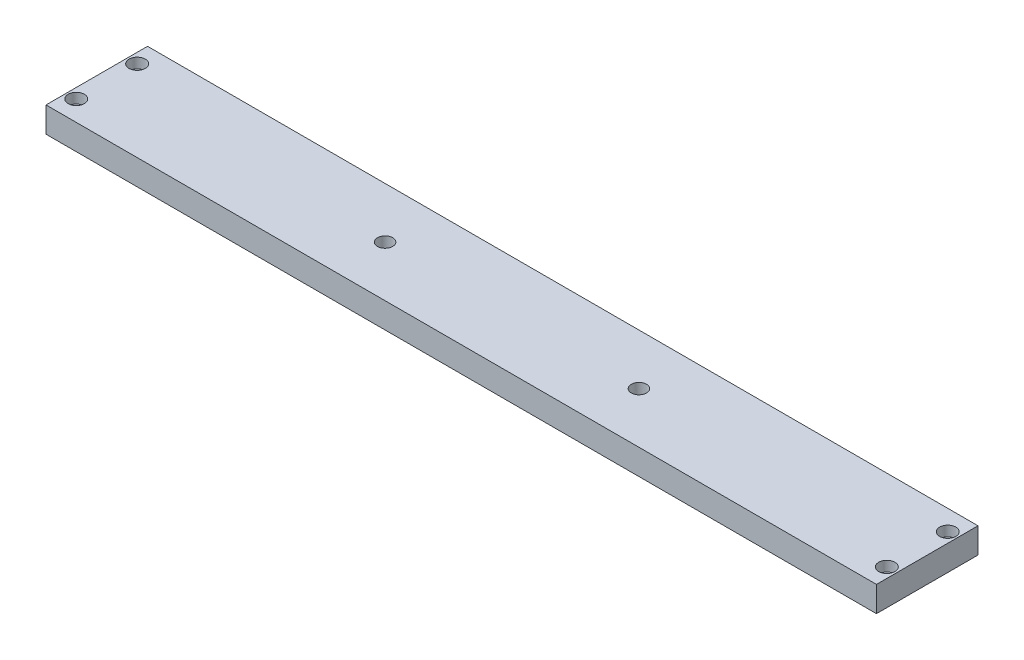
from build123d import *

# Parameters (mm, degrees)
SKETCH1_W           = 163.57
SKETCH1_H           = 20
SKETCH1_R           = 1
BOSS_EXTRUDE1_DEPTH = 5
SKETCH2_R           = 1.6
CUT_EXTRUDE1_DEPTH  = 2
SKETCH3_R           = 1.5
CUT_EXTRUDE2_DEPTH  = 10


with BuildPart() as part:
    # Sketch1 → Boss-Extrude1 (new body)
    with BuildSketch(Plane(origin=(0, 0, 0), x_dir=(1, 0, 0), z_dir=(0, 1, 0))):
        Rectangle(SKETCH1_W, SKETCH1_H)
        with Locations((-79.825, 6)):
            Circle(SKETCH1_R, mode=Mode.SUBTRACT)
        with Locations((-79.825, -6)):
            Circle(SKETCH1_R, mode=Mode.SUBTRACT)
        with Locations((79.825, 6)):
            Circle(SKETCH1_R, mode=Mode.SUBTRACT)
        with Locations((79.825, -6)):
            Circle(SKETCH1_R, mode=Mode.SUBTRACT)
    extrude(amount=BOSS_EXTRUDE1_DEPTH)

    # Sketch2 → Cut-Extrude1 (cut)
    with BuildSketch(Plane(origin=(0, 5, 0), x_dir=(1, 0, 0), z_dir=(0, 1, 0))):
        with Locations((-79.825, 6)):
            Circle(SKETCH2_R)
        with Locations((-79.825, -6)):
            Circle(SKETCH2_R)
        with Locations((79.825, 6)):
            Circle(SKETCH2_R)
        with Locations((79.825, -6)):
            Circle(SKETCH2_R)
    extrude(amount=-CUT_EXTRUDE1_DEPTH, mode=Mode.SUBTRACT)

    # Sketch3 → Cut-Extrude2 (cut)
    with BuildSketch(Plane(origin=(0, 5, 0), x_dir=(1, 0, 0), z_dir=(0, 1, 0))):
        with Locations((-25, 0)):
            Circle(SKETCH3_R)
        with Locations((25, 0)):
            Circle(SKETCH3_R)
    extrude(amount=-CUT_EXTRUDE2_DEPTH, mode=Mode.SUBTRACT)


solid = part.part
